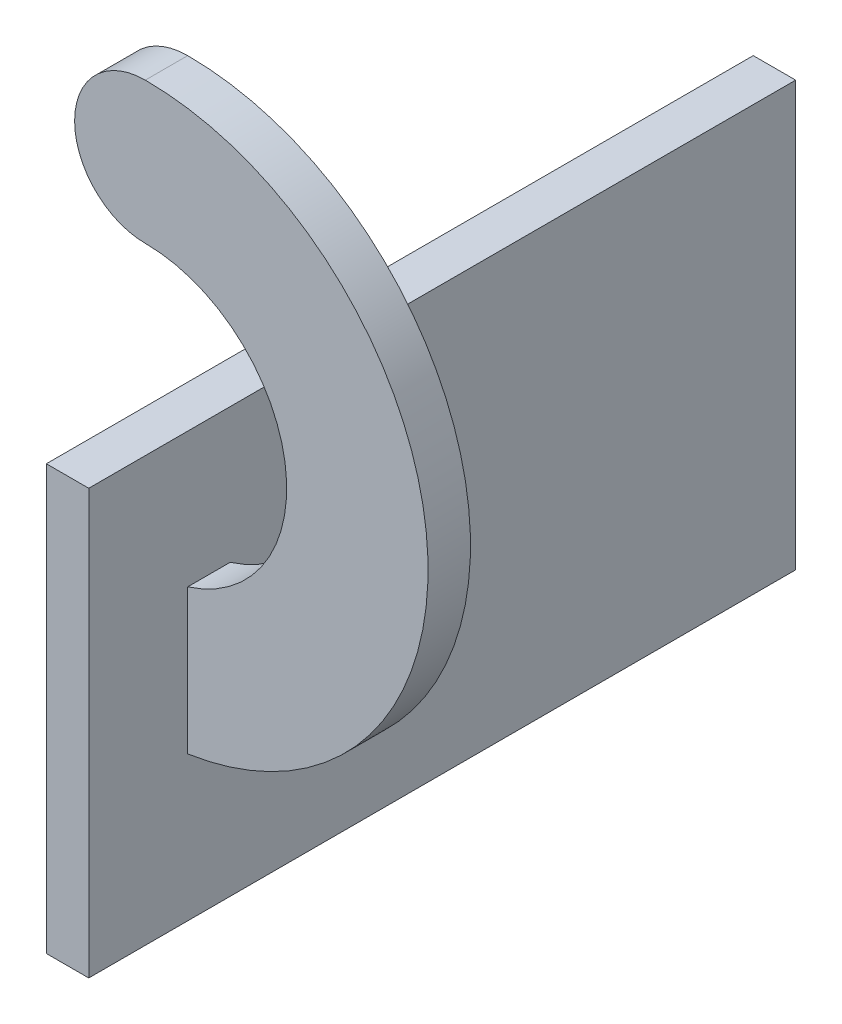
from build123d import *

# Parameters (mm, degrees)
BOSS_EXTRUDE1_DEPTH = 3
SKETCH2_W           = 3
SKETCH2_H           = 10
BOSS_EXTRUDE2_DEPTH = 3
SKETCH3_W           = 3
SKETCH3_H           = 3
BOSS_EXTRUDE3_DEPTH = 20
SKETCH4_W           = 3
SKETCH4_H           = 3
BOSS_EXTRUDE4_DEPTH = 10
SKETCH5_W           = 3
SKETCH5_H           = 30
BOSS_EXTRUDE5_DEPTH = 40
SKETCH6_W           = 3
SKETCH6_H           = 30
BOSS_EXTRUDE6_DEPTH = 7


with BuildPart() as part:
    # Sketch1 → Boss-Extrude1 (new body)
    with BuildSketch(Plane.XY):
        with BuildLine():
            ThreePointArc((0, 10), (10, 0), (0, -10))
            Line((0, -10), (0, -20))
            ThreePointArc((0, -20), (20, 0), (0, 20))
            ThreePointArc((0, 20), (-5, 15), (0, 10))
        make_face()
    extrude(amount=BOSS_EXTRUDE1_DEPTH)

    # Sketch2 → Boss-Extrude2 (add)
    with BuildSketch(Plane.ZY):
        with Locations((1.5, -15)):
            Rectangle(SKETCH2_W, SKETCH2_H)
    extrude(amount=-BOSS_EXTRUDE2_DEPTH)

    # Sketch3 → Boss-Extrude3 (add)
    with BuildSketch(Plane.XZ.offset(20)):
        with Locations((1.5, 1.5)):
            Rectangle(SKETCH3_W, SKETCH3_H)
    extrude(amount=-BOSS_EXTRUDE3_DEPTH)

    # Sketch4 → Boss-Extrude4 (add)
    with BuildSketch(Plane(origin=(0, -20, 0), x_dir=(-1, 0, 0), z_dir=(0, -1, 0))):
        with Locations((-1.5, -1.5)):
            Rectangle(SKETCH4_W, SKETCH4_H)
    extrude(amount=BOSS_EXTRUDE4_DEPTH)

    # Sketch5 → Boss-Extrude5 (add)
    with BuildSketch(Plane(origin=(0, 0, 0), x_dir=(-1, 0, 0), z_dir=(0, 0, -1))):
        with Locations((-1.5, -15)):
            Rectangle(SKETCH5_W, SKETCH5_H)
    extrude(amount=BOSS_EXTRUDE5_DEPTH)

    # Sketch6 → Boss-Extrude6 (add)
    with BuildSketch(Plane.XY.offset(3)):
        with Locations((1.5, -15)):
            Rectangle(SKETCH6_W, SKETCH6_H)
    extrude(amount=BOSS_EXTRUDE6_DEPTH)


solid = part.part
